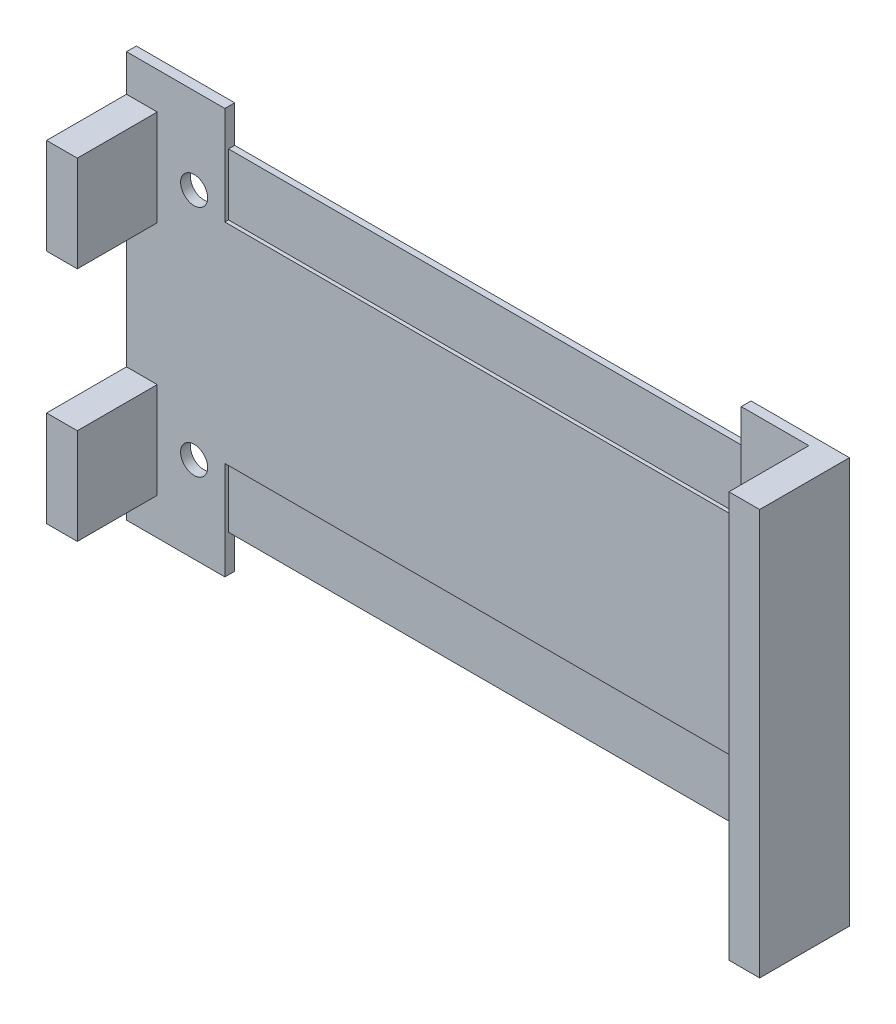
from build123d import *

# Parameters (mm, degrees)
SKETCH1_R           = 1.1
BOSS_EXTRUDE1_DEPTH = 0.8
SKETCH2_W           = 42
SKETCH2_H           = 27
BOSS_EXTRUDE2_DEPTH = 0.5
SKETCH3_W           = 2.5
SKETCH3_H           = 33
SKETCH3_H_2         = 7.8
BOSS_EXTRUDE3_DEPTH = 6.5


with BuildPart() as part:
    # Sketch1 → Boss-Extrude1 (new body)
    with BuildSketch(Plane.XY.offset(-2.3)):
        Polygon((52, -5), (55, -5), (55, 28), (52, 28), (47, 28), (47, 20), (5, 20), (5, 28), (0, 28), (-3, 28), (-3, -5), (0, -5), (5, -5), (5, 3), (47, 3), (47, -5), align=None)
        with Locations((49.5, 2)):
            Circle(SKETCH1_R, mode=Mode.SUBTRACT)
        with Locations((49.5, 21)):
            Circle(SKETCH1_R, mode=Mode.SUBTRACT)
        with Locations((2.5, 2)):
            Circle(SKETCH1_R, mode=Mode.SUBTRACT)
        with Locations((2.5, 21)):
            Circle(SKETCH1_R, mode=Mode.SUBTRACT)
    extrude(amount=BOSS_EXTRUDE1_DEPTH)

    # Sketch2 → Boss-Extrude2 (add)
    with BuildSketch(Plane.XY.offset(-2.3)):
        with Locations((26, 11.5)):
            Rectangle(SKETCH2_W, SKETCH2_H)
    extrude(amount=BOSS_EXTRUDE2_DEPTH)

    # Sketch3 → Boss-Extrude3 (add)
    with BuildSketch(Plane.XY.offset(-1.5)):
        with Locations((53.75, 11.5)):
            Rectangle(SKETCH3_W, SKETCH3_H)
        with Locations((-1.75, 1.9)):
            Rectangle(SKETCH3_W, SKETCH3_H_2)
        with Locations((-1.75, 21.1)):
            Rectangle(SKETCH3_W, SKETCH3_H_2)
    extrude(amount=BOSS_EXTRUDE3_DEPTH)


solid = part.part
